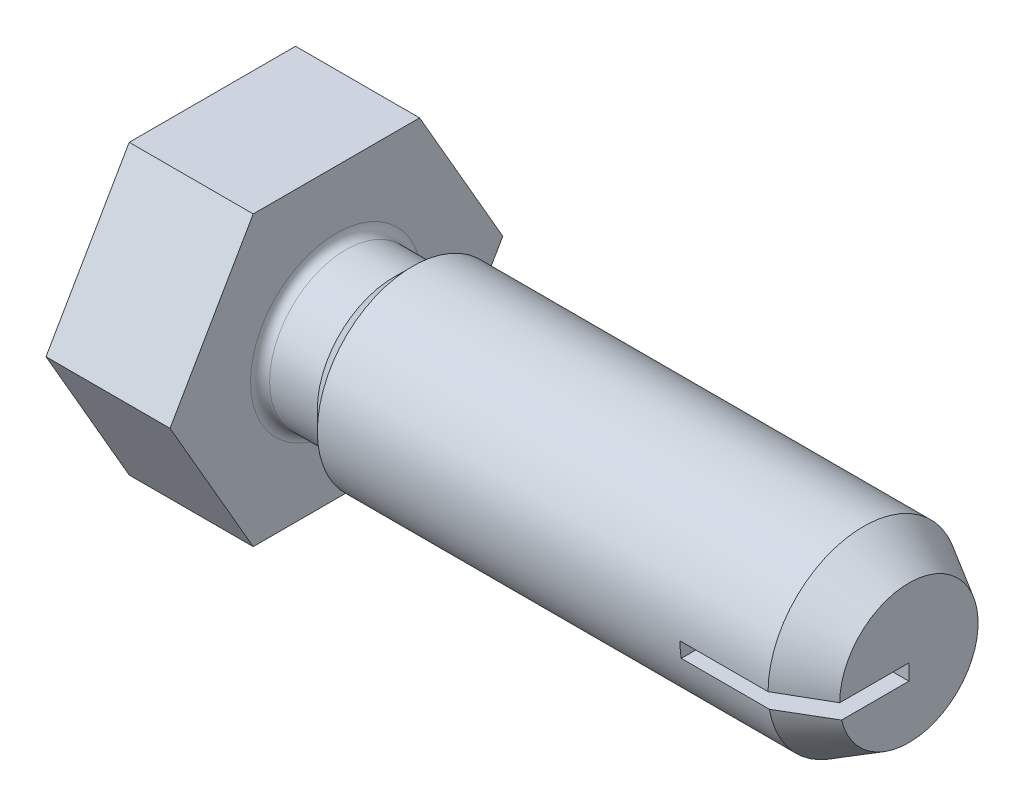
from build123d import *

# Parameters (mm, degrees)
EXTRUDE1_DEPTH           = 1.3
SKETCH11_W               = 1.4
SKETCH11_H               = 0.166666667
POINT_CUT_EXTRUDE8_DEPTH = 2.743597813
SKETCH16_R               = 1.208
CUT_EXTRUDE1_DEPTH       = 0.26


with BuildPart() as part:
    # Sketch1 → base-Revolve (revolve)
    with BuildSketch(Plane.XY):
        with BuildLine():
            Line((6, 1), (6, 0))
            Line((6, 0), (0, 0))
            Line((0, 0), (-1.04, 0))
            Line((-1.04, 0), (-1.3, 0))
            Line((-1.3, 0), (-1.3, 1.51))
            Line((-1.3, 1.51), (0, 1.51))
            Line((0, 1.51), (0, 0.9))
            ThreePointArc((0, 0.9), (0.029289322, 0.829289322), (0.1, 0.8))
            Line((0.1, 0.8), (0.6, 0.8))
            Line((0.6, 0.8), (0.8, 1))
            Line((0.8, 1), (6, 1))
        make_face()
    revolve(axis=Axis((0, 0, 0), (1, 0, 0)))

    # Sketch15 → Extrude1 (add)
    with BuildSketch(Plane.ZY.offset(1.3)):
        Polygon((-0.871798906, 1.51), (-1.743597813, 0), (-0.871798906, -1.51), (0.871798906, -1.51), (1.743597813, 0), (0.871798906, 1.51), align=None)
    extrude(amount=-EXTRUDE1_DEPTH)

    # Sketch8 → point_Cut-Revolve1 (revolve, cut)
    with BuildSketch(Plane.XY):
        Polygon((6, 0), (6.508, 0), (6.508, 1.508), (5.523686028, 1.508), (5.523686028, 1), (6, 0.725), align=None)
    revolve(axis=Axis((0, 0, 0), (1, 0, 0)), mode=Mode.SUBTRACT)

    # Sketch11 → point_Cut-Extrude8 (cut, through all)
    with BuildSketch(Plane.XY):
        with Locations((5.3, -0.083333334)):
            Rectangle(SKETCH11_W, SKETCH11_H)
    extrude(amount=POINT_CUT_EXTRUDE8_DEPTH, mode=Mode.SUBTRACT)

    # Sketch16 → Cut-Extrude1 (cut)
    with BuildSketch(Plane.ZY.offset(1.3)):
        Circle(SKETCH16_R)
    extrude(amount=-CUT_EXTRUDE1_DEPTH, mode=Mode.SUBTRACT)


solid = part.part
